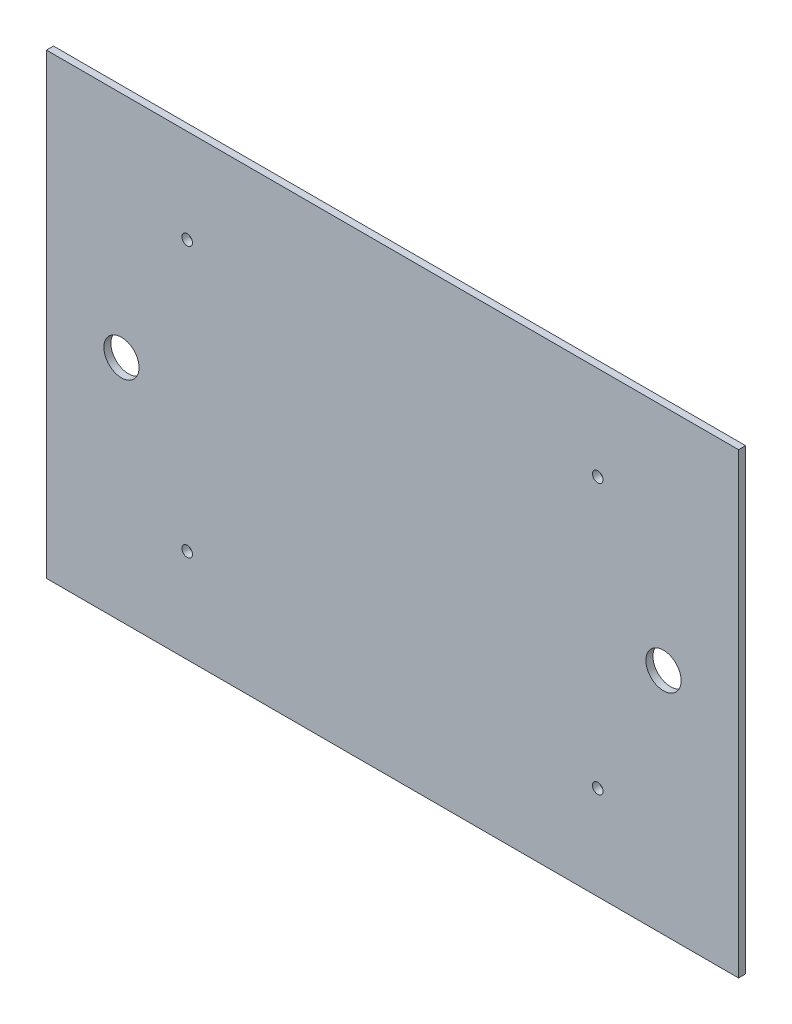
from build123d import *

# Parameters (mm, degrees)
ESQUISSE1_W        = 295
ESQUISSE1_H        = 195
ESQUISSE1_R        = 2.25
ESQUISSE1_R_2      = 7.5
BOSS_EXTRU_1_DEPTH = 3


with BuildPart() as part:
    # Esquisse1 → Boss.-Extru.1 (new body)
    with BuildSketch(Plane.XY):
        with Locations((147.5, -97.5)):
            Rectangle(ESQUISSE1_W, ESQUISSE1_H)
        with Locations((60, -40)):
            Circle(ESQUISSE1_R, mode=Mode.SUBTRACT)
        with Locations((235, -40)):
            Circle(ESQUISSE1_R, mode=Mode.SUBTRACT)
        with Locations((235, -155)):
            Circle(ESQUISSE1_R, mode=Mode.SUBTRACT)
        with Locations((60, -155)):
            Circle(ESQUISSE1_R, mode=Mode.SUBTRACT)
        with Locations((32, -97.5)):
            Circle(ESQUISSE1_R_2, mode=Mode.SUBTRACT)
        with Locations((263, -97.5)):
            Circle(ESQUISSE1_R_2, mode=Mode.SUBTRACT)
    extrude(amount=BOSS_EXTRU_1_DEPTH)


solid = part.part
